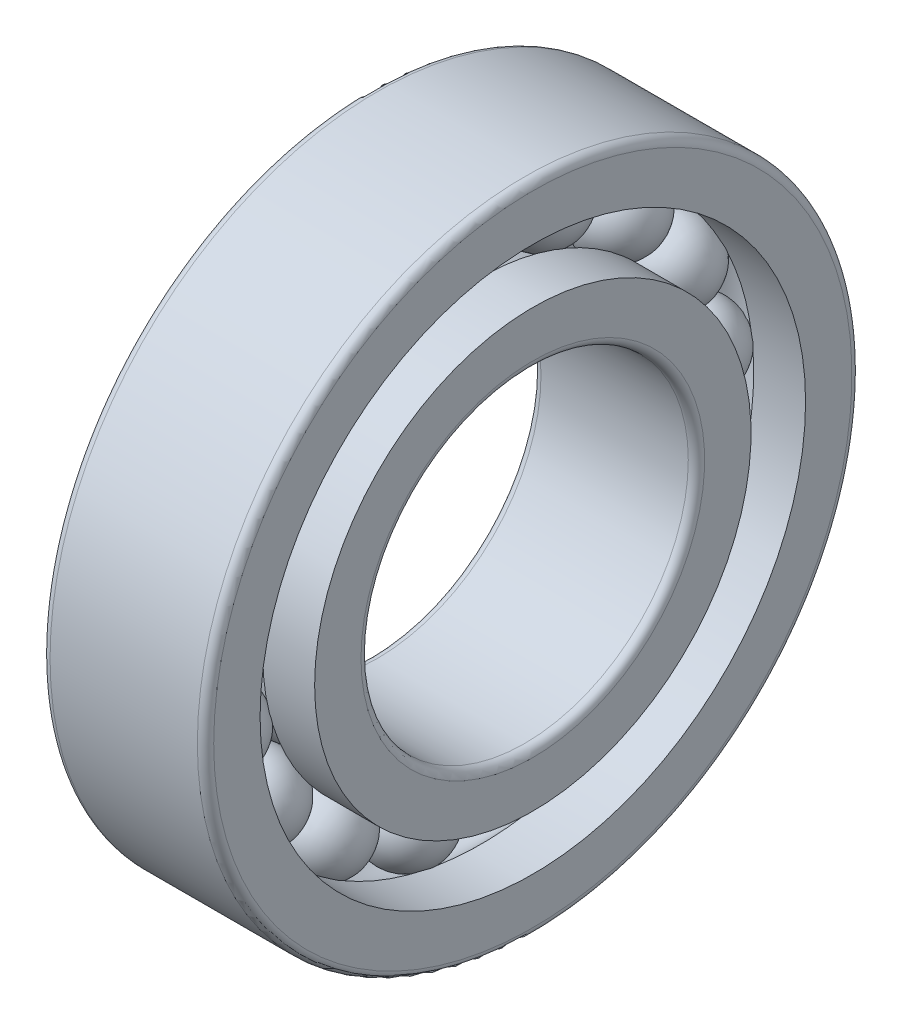
from build123d import *

# Parameters (mm, degrees)
CIRCULAR_PATTERN1_COUNT = 17
FILLET1_R               = 0.2


with BuildPart() as part:
    # Sketch1 → Revolve1 (revolve)
    with BuildSketch(Plane.XY):
        with BuildLine():
            Line((-1, 6), (1, 6))
            ThreePointArc((1, 6), (0, 7), (-1, 6))
        make_face()
    revolve1 = revolve(axis=Axis((-4.596601835, 6, 0), (1, 0, 0)))

    # Sketch2 → Revolve2 (revolve)
    with BuildSketch(Plane.XY, mode=Mode.PRIVATE) as revolve2_sk:
        with BuildLine():
            Line((-2, 5.333333333), (-2, 4))
            Line((-2, 4), (2, 4))
            Line((2, 4), (2, 5.333333333))
            Line((2, 5.333333333), (0.731884933, 5.333333333))
            ThreePointArc((0.731884933, 5.333333333), (0, 5.01), (-0.731884933, 5.333333333))
            Line((-0.731884933, 5.333333333), (-2, 5.333333333))
        make_face()
    revolve(revolve2_sk.sketch.rotate(Axis((-6.971390126, 0, 0), (1, 0, 0)), 90), axis=Axis((-6.971390126, 0, 0), (1, 0, 0)))

    # Sketch3 → Revolve3 (revolve)
    with BuildSketch(Plane.XY, mode=Mode.PRIVATE) as revolve3_sk:
        with BuildLine():
            Line((-2, 8), (2, 8))
            Line((2, 8), (2, 6.666666667))
            Line((2, 6.666666667), (0.731884933, 6.666666667))
            ThreePointArc((0.731884933, 6.666666667), (0, 6.99), (-0.731884933, 6.666666667))
            Line((-0.731884933, 6.666666667), (-2, 6.666666667))
            Line((-2, 6.666666667), (-2, 8))
        make_face()
    revolve(revolve3_sk.sketch.rotate(Axis((-8.710676495, 0, 0), (1, 0, 0)), 90), axis=Axis((-8.710676495, 0, 0), (1, 0, 0)))

    # Circular-Pattern1: Revolve1 ×17 about axis
    circular_pattern1_axis = Axis((0, 0, 0), (1, 0, 0))
    for i in range(1, CIRCULAR_PATTERN1_COUNT):
        add(revolve1.rotate(circular_pattern1_axis, i * 360 / CIRCULAR_PATTERN1_COUNT))

    # Fillet1
    fillet1_edges = [part.edges().sort_by_distance(p)[0] for p in [
        (-2, 0, -8),
        (2, 0, -8),
        (-2, 0, -4),
        (2, 0, -4),
    ]]
    fillet(fillet1_edges, radius=FILLET1_R)


solid = part.part
